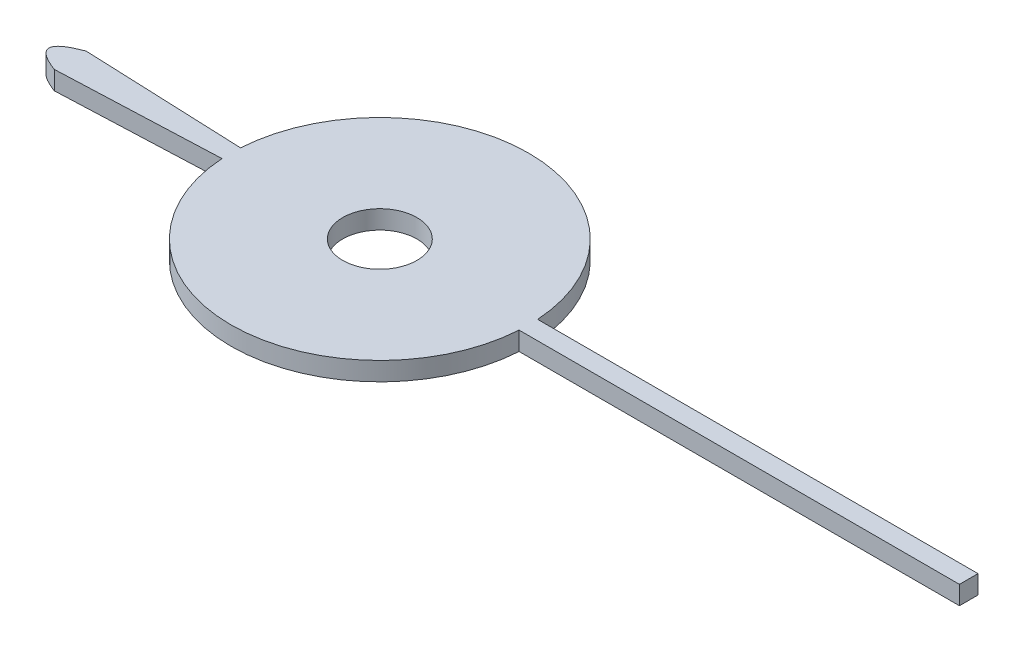
from build123d import *

# Parameters (mm, degrees)
BOSS_EXTRUDE2_DEPTH = 0.5
SKETCH3_R           = 1
CUT_EXTRUDE2_DEPTH  = 1.5000001


with BuildPart() as part:
    # Sketch1 → Boss-Extrude2 (new body)
    with BuildSketch(Plane(origin=(0, 0, 0), x_dir=(1, 0, 0), z_dir=(0, 1, 0))):
        with BuildLine():
            Line((15.859342687, 0.25), (4, 0.25))
            ThreePointArc((4, 0.25), (0, 4.007804885), (-4, 0.25))
            Line((-4, 0.25), (-8.33886799, 0.428130321))
            add(Edge.make_bspline(
                [(-8.33886799, 0.428130321), (-9.480171403, 0), (-8.33886799, -0.428130321)],
                knots=[0, 0, 0, 1, 1, 1], degree=2))
            Line((-8.33886799, -0.428130321), (-4, -0.25))
            ThreePointArc((-4, -0.25), (0, -4.007804885), (4, -0.25))
            Line((4, -0.25), (15.859342687, -0.25))
            Line((15.859342687, -0.25), (15.859342687, 0.25))
        make_face()
    extrude(amount=BOSS_EXTRUDE2_DEPTH)

    # Sketch3 → Cut-Extrude2 (cut, through all)
    with BuildSketch(Plane(origin=(0, 0.5, 0), x_dir=(1, 0, 0), z_dir=(0, 1, 0))):
        Circle(SKETCH3_R)
    extrude(amount=-CUT_EXTRUDE2_DEPTH, mode=Mode.SUBTRACT)


solid = part.part
